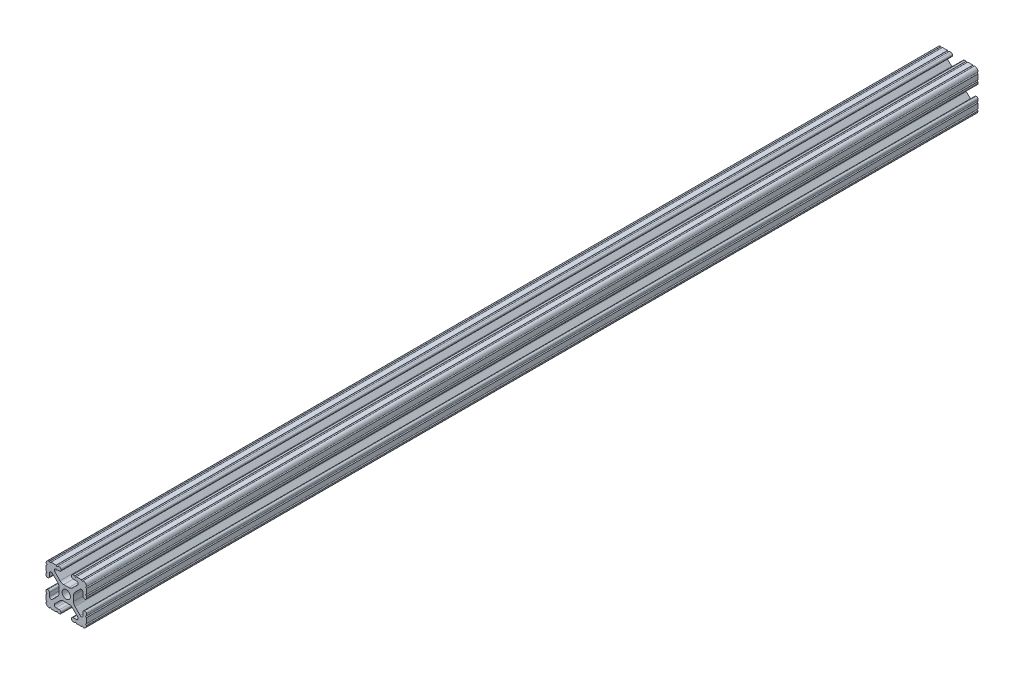
from build123d import *

# Parameters (mm, degrees)
SKETCH1_R               = 2.6035
BOSS_EXTRUDE1_DEPTH     = 279.4
SKETCH2_R               = 3.175
CUT_EXTRUDE1_DEPTH      = 281.216604679
CUT_EXTRUDE2_DEPTH      = 281.216604785
CUT_EXTRUDE2_DEPTH_BACK = 2.54
SKETCH2_3_R             = 3.175


with BuildPart() as part:
    # Sketch1 → Boss-Extrude1 (new, symmetric)
    with BuildSketch(Plane.XY):
        with BuildLine():
            Line((-7.179650497, -8.645192506), (-3.952270251, -5.423690499))
            ThreePointArc((-3.952270251, -5.423690499), (-2.922936451, -4.736929036), (-1.709253557, -4.4958))
            Line((-1.709253557, -4.4958), (1.709253557, -4.4958))
            ThreePointArc((1.709253557, -4.4958), (2.922936451, -4.736929036), (3.952270251, -5.423690499))
            Line((3.952270251, -5.423690499), (7.179650497, -8.645192506))
            ThreePointArc((7.179650497, -8.645192506), (7.41473083, -9.822813117), (6.416408329, -10.4902))
            Line((6.416408329, -10.4902), (4.287512407, -10.4902))
            ThreePointArc((4.287512407, -10.4902), (3.54574862, -10.79744862), (3.2385, -11.539212407))
            Line((3.2385, -11.539212407), (3.2385, -11.650987593))
            ThreePointArc((3.2385, -11.650987593), (3.54574862, -12.39275138), (4.287512407, -12.7))
            Line((4.287512407, -12.7), (5.317126718, -12.7))
            ThreePointArc((5.317126718, -12.7), (5.825126718, -12.192), (6.333126718, -12.7))
            Line((6.333126718, -12.7), (9.550443118, -12.7))
            ThreePointArc((9.550443118, -12.7), (10.058366869, -12.192000006), (10.566443095, -12.699847501))
            ThreePointArc((10.566443095, -12.699847501), (12.082537762, -12.08250727), (12.699846982, -10.566399977))
            ThreePointArc((12.699846982, -10.566399977), (12.192000006, -10.058323491), (12.7, -9.5504))
            Line((12.7, -9.5504), (12.7, -6.3330836))
            ThreePointArc((12.7, -6.3330836), (12.192, -5.8250836), (12.7, -5.3170836))
            Line((12.7, -5.3170836), (12.7, -4.287469289))
            ThreePointArc((12.7, -4.287469289), (12.39275138, -3.545705502), (11.650987593, -3.238456882))
            Line((11.650987593, -3.238456882), (11.539212407, -3.238456882))
            ThreePointArc((11.539212407, -3.238456882), (10.79744862, -3.545705502), (10.4902, -4.287469289))
            Line((10.4902, -4.287469289), (10.4902, -6.402089023))
            ThreePointArc((10.4902, -6.402089023), (9.856505071, -7.351067942), (8.737131347, -7.129408934))
            Line((8.737131347, -7.129408934), (5.441005833, -3.840816462))
            ThreePointArc((5.441005833, -3.840816462), (4.750877967, -2.809883091), (4.5085, -1.593185507))
            Line((4.5085, -1.593185507), (4.5085, 1.593185507))
            ThreePointArc((4.5085, 1.593185507), (4.750877967, 2.809883091), (5.441005833, 3.840816462))
            Line((5.441005833, 3.840816462), (8.737131347, 7.129408934))
            ThreePointArc((8.737131347, 7.129408934), (9.856505071, 7.351067942), (10.4902, 6.402089023))
            Line((10.4902, 6.402089023), (10.4902, 4.287469289))
            ThreePointArc((10.4902, 4.287469289), (10.79744862, 3.545705502), (11.539212407, 3.238456882))
            Line((11.539212407, 3.238456882), (11.650987593, 3.238456882))
            ThreePointArc((11.650987593, 3.238456882), (12.39275138, 3.545705502), (12.7, 4.287469289))
            Line((12.7, 4.287469289), (12.7, 5.3170836))
            ThreePointArc((12.7, 5.3170836), (12.192, 5.8250836), (12.7, 6.3330836))
            Line((12.7, 6.3330836), (12.7, 9.5504))
            ThreePointArc((12.7, 9.5504), (12.192000006, 10.058323491), (12.699846982, 10.566399977))
            ThreePointArc((12.699846982, 10.566399977), (12.082537762, 12.08250727), (10.566443095, 12.699847501))
            ThreePointArc((10.566443095, 12.699847501), (10.058366869, 12.192000006), (9.550443118, 12.7))
            Line((9.550443118, 12.7), (6.333126718, 12.7))
            ThreePointArc((6.333126718, 12.7), (5.825126718, 12.192), (5.317126718, 12.7))
            Line((5.317126718, 12.7), (4.287512407, 12.7))
            ThreePointArc((4.287512407, 12.7), (3.54574862, 12.39275138), (3.2385, 11.650987593))
            Line((3.2385, 11.650987593), (3.2385, 11.539212407))
            ThreePointArc((3.2385, 11.539212407), (3.54574862, 10.79744862), (4.287512407, 10.4902))
            Line((4.287512407, 10.4902), (6.476788598, 10.4902))
            ThreePointArc((6.476788598, 10.4902), (7.432222385, 9.85140422), (7.207036008, 8.724370562))
            Line((7.207036008, 8.724370562), (3.898272566, 5.423169045))
            ThreePointArc((3.898272566, 5.423169045), (2.869120213, 4.736787962), (1.655778399, 4.4958))
            Line((1.655778399, 4.4958), (-1.655778399, 4.4958))
            ThreePointArc((-1.655778399, 4.4958), (-2.869120213, 4.736787962), (-3.898272566, 5.423169045))
            Line((-3.898272566, 5.423169045), (-7.207036008, 8.724370562))
            ThreePointArc((-7.207036008, 8.724370562), (-7.432222385, 9.85140422), (-6.476788598, 10.4902))
            Line((-6.476788598, 10.4902), (-4.287512407, 10.4902))
            ThreePointArc((-4.287512407, 10.4902), (-3.54574862, 10.79744862), (-3.2385, 11.539212407))
            Line((-3.2385, 11.539212407), (-3.2385, 11.650987593))
            ThreePointArc((-3.2385, 11.650987593), (-3.54574862, 12.39275138), (-4.287512407, 12.7))
            Line((-4.287512407, 12.7), (-5.317126718, 12.7))
            ThreePointArc((-5.317126718, 12.7), (-5.825126718, 12.192), (-6.333126718, 12.7))
            Line((-6.333126718, 12.7), (-9.550443118, 12.7))
            ThreePointArc((-9.550443118, 12.7), (-10.058366869, 12.192000006), (-10.566443095, 12.699847501))
            ThreePointArc((-10.566443095, 12.699847501), (-12.082537762, 12.08250727), (-12.699846982, 10.566399977))
            ThreePointArc((-12.699846982, 10.566399977), (-12.192000006, 10.058323491), (-12.7, 9.5504))
            Line((-12.7, 9.5504), (-12.7, 6.3330836))
            ThreePointArc((-12.7, 6.3330836), (-12.192, 5.8250836), (-12.7, 5.3170836))
            Line((-12.7, 5.3170836), (-12.7, 4.287469289))
            ThreePointArc((-12.7, 4.287469289), (-12.39275138, 3.545705502), (-11.650987593, 3.238456882))
            Line((-11.650987593, 3.238456882), (-11.539212407, 3.238456882))
            ThreePointArc((-11.539212407, 3.238456882), (-10.79744862, 3.545705502), (-10.4902, 4.287469289))
            Line((-10.4902, 4.287469289), (-10.4902, 6.402089023))
            ThreePointArc((-10.4902, 6.402089023), (-9.856505071, 7.351067942), (-8.737131347, 7.129408934))
            Line((-8.737131347, 7.129408934), (-5.441005833, 3.840816462))
            ThreePointArc((-5.441005833, 3.840816462), (-4.750877967, 2.809883091), (-4.5085, 1.593185507))
            Line((-4.5085, 1.593185507), (-4.5085, -1.593185507))
            ThreePointArc((-4.5085, -1.593185507), (-4.750877967, -2.809883091), (-5.441005833, -3.840816462))
            Line((-5.441005833, -3.840816462), (-8.737131347, -7.129408934))
            ThreePointArc((-8.737131347, -7.129408934), (-9.856505071, -7.351067942), (-10.4902, -6.402089023))
            Line((-10.4902, -6.402089023), (-10.4902, -4.287469289))
            ThreePointArc((-10.4902, -4.287469289), (-10.79744862, -3.545705502), (-11.539212407, -3.238456882))
            Line((-11.539212407, -3.238456882), (-11.650987593, -3.238456882))
            ThreePointArc((-11.650987593, -3.238456882), (-12.39275138, -3.545705502), (-12.7, -4.287469289))
            Line((-12.7, -4.287469289), (-12.7, -5.3170836))
            ThreePointArc((-12.7, -5.3170836), (-12.192, -5.8250836), (-12.7, -6.3330836))
            Line((-12.7, -6.3330836), (-12.7, -9.5504))
            ThreePointArc((-12.7, -9.5504), (-12.192000006, -10.058323491), (-12.699846982, -10.566399977))
            ThreePointArc((-12.699846982, -10.566399977), (-12.082537762, -12.08250727), (-10.566443095, -12.699847501))
            ThreePointArc((-10.566443095, -12.699847501), (-10.058366869, -12.192000006), (-9.550443118, -12.7))
            Line((-9.550443118, -12.7), (-6.333126718, -12.7))
            ThreePointArc((-6.333126718, -12.7), (-5.825126718, -12.192), (-5.317126718, -12.7))
            Line((-5.317126718, -12.7), (-4.287512407, -12.7))
            ThreePointArc((-4.287512407, -12.7), (-3.54574862, -12.39275138), (-3.2385, -11.650987593))
            Line((-3.2385, -11.650987593), (-3.2385, -11.539212407))
            ThreePointArc((-3.2385, -11.539212407), (-3.54574862, -10.79744862), (-4.287512407, -10.4902))
            Line((-4.287512407, -10.4902), (-6.416408329, -10.4902))
            ThreePointArc((-6.416408329, -10.4902), (-7.41473083, -9.822813117), (-7.179650497, -8.645192506))
        make_face()
        Circle(SKETCH1_R, mode=Mode.SUBTRACT)
    extrude(amount=BOSS_EXTRUDE1_DEPTH, both=True)

    # Sketch2 → Cut-Extrude1 (cut, through all)
    with BuildSketch(Plane(origin=(0, 4.4958, 0), x_dir=(1, 0, 0), z_dir=(0, 1, 0))):
        with Locations((0.240663446, 228.6)):
            Circle(SKETCH2_R)
        with Locations((0, -228.6)):
            Circle(SKETCH2_R)
    extrude(amount=-CUT_EXTRUDE1_DEPTH, mode=Mode.SUBTRACT)

    # Sketch2_3 → Cut-Extrude2 (cut, two sides: drawn at the far end of the back side and taken through both)
    with BuildSketch(Plane(origin=(0, 4.4958, 0), x_dir=(1, 0, 0), z_dir=(0, 1, 0)).offset(-CUT_EXTRUDE2_DEPTH_BACK)):
        with Locations((0.240663446, 228.6)):
            Circle(SKETCH2_3_R)
        with Locations((0, -228.6)):
            Circle(SKETCH2_3_R)
    extrude(amount=CUT_EXTRUDE2_DEPTH + CUT_EXTRUDE2_DEPTH_BACK, mode=Mode.SUBTRACT)


solid = part.part
